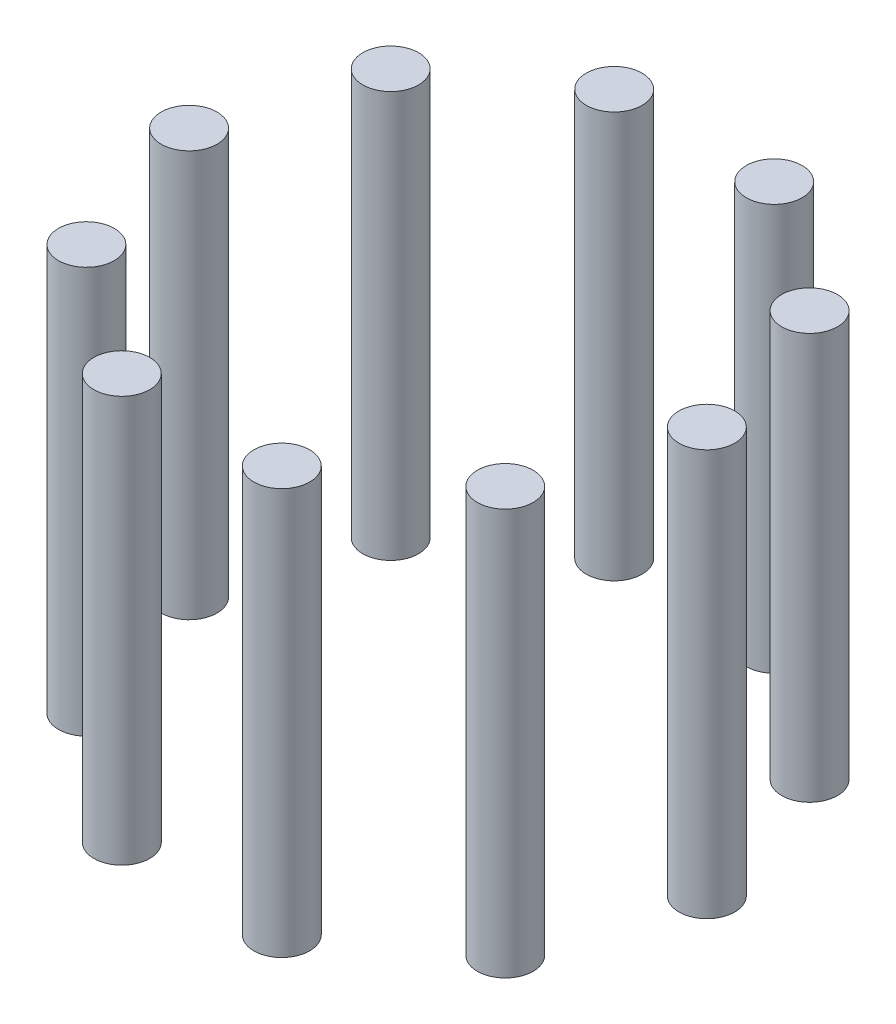
from build123d import *

# Parameters (mm, degrees)
SKETCH1_R              = 5.5
BOSS_EXTRUDE1_DEPTH    = 80
BOSS_EXTRUDE1_2_DEPTH  = 80
BOSS_EXTRUDE1_3_DEPTH  = 80
BOSS_EXTRUDE1_4_DEPTH  = 80
BOSS_EXTRUDE1_5_DEPTH  = 80
BOSS_EXTRUDE1_6_DEPTH  = 80
BOSS_EXTRUDE1_7_DEPTH  = 80
BOSS_EXTRUDE1_8_DEPTH  = 80
BOSS_EXTRUDE1_9_DEPTH  = 80
BOSS_EXTRUDE1_10_DEPTH = 80


with BuildPart() as part:
    # Sketch1 → Boss-Extrude1 (new body)
    with BuildSketch(Plane(origin=(0, 0, 0), x_dir=(1, 0, 0), z_dir=(0, 1, 0))):
        with Locations((51, 0)):
            Circle(SKETCH1_R)
    extrude(amount=BOSS_EXTRUDE1_DEPTH)


with BuildPart() as body_2:
    # Sketch1 → Boss-Extrude1 2 (new body)
    with BuildSketch(Plane(origin=(0, 0, 0), x_dir=(1, 0, 0), z_dir=(0, 1, 0))):
        with Locations((41.259866713, -29.977047867)):
            Circle(SKETCH1_R)
    extrude(amount=BOSS_EXTRUDE1_2_DEPTH)


with BuildPart() as body_3:
    # Sketch1 → Boss-Extrude1 3 (new body)
    with BuildSketch(Plane(origin=(0, 0, 0), x_dir=(1, 0, 0), z_dir=(0, 1, 0))):
        with Locations((15.759866713, -48.503882331)):
            Circle(SKETCH1_R)
    extrude(amount=BOSS_EXTRUDE1_3_DEPTH)


with BuildPart() as body_4:
    # Sketch1 → Boss-Extrude1 4 (new body)
    with BuildSketch(Plane(origin=(0, 0, 0), x_dir=(1, 0, 0), z_dir=(0, 1, 0))):
        with Locations((-15.759866713, -48.503882331)):
            Circle(SKETCH1_R)
    extrude(amount=BOSS_EXTRUDE1_4_DEPTH)


with BuildPart() as body_5:
    # Sketch1 → Boss-Extrude1 5 (new body)
    with BuildSketch(Plane(origin=(0, 0, 0), x_dir=(1, 0, 0), z_dir=(0, 1, 0))):
        with Locations((-41.259866713, -29.977047867)):
            Circle(SKETCH1_R)
    extrude(amount=BOSS_EXTRUDE1_5_DEPTH)


with BuildPart() as body_6:
    # Sketch1 → Boss-Extrude1 6 (new body)
    with BuildSketch(Plane(origin=(0, 0, 0), x_dir=(1, 0, 0), z_dir=(0, 1, 0))):
        with Locations((-51, 0)):
            Circle(SKETCH1_R)
    extrude(amount=BOSS_EXTRUDE1_6_DEPTH)


with BuildPart() as body_7:
    # Sketch1 → Boss-Extrude1 7 (new body)
    with BuildSketch(Plane(origin=(0, 0, 0), x_dir=(1, 0, 0), z_dir=(0, 1, 0))):
        with Locations((-41.259866713, 29.977047867)):
            Circle(SKETCH1_R)
    extrude(amount=BOSS_EXTRUDE1_7_DEPTH)


with BuildPart() as body_8:
    # Sketch1 → Boss-Extrude1 8 (new body)
    with BuildSketch(Plane(origin=(0, 0, 0), x_dir=(1, 0, 0), z_dir=(0, 1, 0))):
        with Locations((-15.759866713, 48.503882331)):
            Circle(SKETCH1_R)
    extrude(amount=BOSS_EXTRUDE1_8_DEPTH)


with BuildPart() as body_9:
    # Sketch1 → Boss-Extrude1 9 (new body)
    with BuildSketch(Plane(origin=(0, 0, 0), x_dir=(1, 0, 0), z_dir=(0, 1, 0))):
        with Locations((15.759866713, 48.503882331)):
            Circle(SKETCH1_R)
    extrude(amount=BOSS_EXTRUDE1_9_DEPTH)


with BuildPart() as body_10:
    # Sketch1 → Boss-Extrude1 10 (new body)
    with BuildSketch(Plane(origin=(0, 0, 0), x_dir=(1, 0, 0), z_dir=(0, 1, 0))):
        with Locations((41.259866713, 29.977047867)):
            Circle(SKETCH1_R)
    extrude(amount=BOSS_EXTRUDE1_10_DEPTH)


solid = Compound([part.part, body_2.part, body_3.part, body_4.part, body_5.part, body_6.part, body_7.part, body_8.part, body_9.part, body_10.part])
